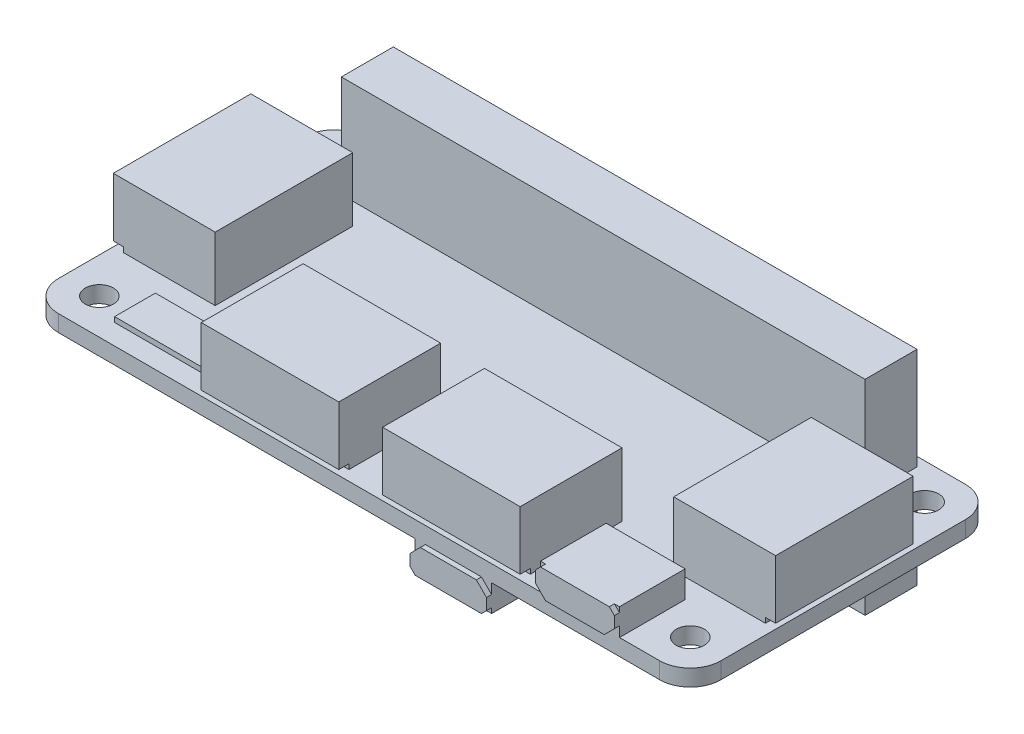
from build123d import *

# Parameters (mm, degrees)
EXTRUDE_1_DEPTH     = 1.62
CUT_EXTRUDE_1_REACH = 3.62
SKETCH_2_R          = 1.375
SKETCH_11_W         = 51.4
SKETCH_11_H         = 5.1
EXTRUDE_9_DEPTH     = 8.45
SKETCH_12_W         = 51.4
SKETCH_12_H         = 5.1
EXTRUDE_10_DEPTH    = 10
SKETCH_13_W         = 10
SKETCH_13_H         = 13.5
SKETCH_13_W_2       = 13.5
SKETCH_13_H_2       = 10
EXTRUDE_12_DEPTH    = 6.25
SKETCH_14_W         = 13.5
SKETCH_14_H         = 0.5
CUT_EXTRUDE_2_DEPTH = 1
SKETCH_15_W         = 13.5
SKETCH_15_H         = 0.5
CUT_EXTRUDE_3_DEPTH = 1
SKETCH_16_W         = 13.5
SKETCH_16_H         = 0.5
CUT_EXTRUDE_4_DEPTH = 1
SKETCH_17_W         = 7.75
SKETCH_17_H         = 6.44
EXTRUDE_13_DEPTH    = 2.62
EXTRUDE_14_DEPTH    = 0.5
SKETCH_19_W         = 8.5
SKETCH_19_H         = 4
EXTRUDE_15_DEPTH    = 0.5
SKETCH_20_W         = 7.5
SKETCH_20_H         = 5.146384945
EXTRUDE_16_DEPTH    = 2.62
EXTRUDE_17_DEPTH    = 0.5


with BuildPart() as part:
    # 草图1 → 凸台-拉伸1 (new body)
    with BuildSketch(Plane(origin=(0, 0, 0), x_dir=(1, 0, 0), z_dir=(0, 1, 0))):
        with BuildLine():
            Line((-29.5, 15), (29.5, 15))
            ThreePointArc((29.5, 15), (31.621320344, 14.121320344), (32.5, 12))
            Line((32.5, 12), (32.5, -12))
            ThreePointArc((32.5, -12), (31.621320344, -14.121320344), (29.5, -15))
            Line((29.5, -15), (-29.5, -15))
            ThreePointArc((-29.5, -15), (-31.621320344, -14.121320344), (-32.5, -12))
            Line((-32.5, -12), (-32.5, 12))
            ThreePointArc((-32.5, 12), (-31.621320344, 14.121320344), (-29.5, 15))
        make_face()
    extrude(amount=EXTRUDE_1_DEPTH)

    # 草图2 → 切除-拉伸1 (cut, up to next)
    with BuildSketch(Plane(origin=(0, 1.62, 0), x_dir=(1, 0, 0), z_dir=(0, 1, 0)), mode=Mode.PRIVATE) as cut_extrude_1_sk1:
        with Locations(Location((29, -11.5, 0), (0, 0, 270))):  # turned: the seam where the file's is
            Circle(SKETCH_2_R)
    cut_extrude_1_tool1 = extrude(cut_extrude_1_sk1.sketch, amount=-CUT_EXTRUDE_1_REACH, mode=Mode.PRIVATE) & part.part
    add(cut_extrude_1_tool1.solids().sort_by_distance((29, 1.62, 11.5))[0], mode=Mode.SUBTRACT)
    # 草图2 → 切除-拉伸1 (cut, up to next)
    with BuildSketch(Plane(origin=(0, 1.62, 0), x_dir=(1, 0, 0), z_dir=(0, 1, 0)), mode=Mode.PRIVATE) as cut_extrude_1_sk2:
        with Locations(Location((29, 11.5, 0), (0, 0, 270))):  # turned: the seam where the file's is
            Circle(SKETCH_2_R)
    cut_extrude_1_tool2 = extrude(cut_extrude_1_sk2.sketch, amount=-CUT_EXTRUDE_1_REACH, mode=Mode.PRIVATE) & part.part
    add(cut_extrude_1_tool2.solids().sort_by_distance((29, 1.62, -11.5))[0], mode=Mode.SUBTRACT)
    # 草图2 → 切除-拉伸1 (cut, up to next)
    with BuildSketch(Plane(origin=(0, 1.62, 0), x_dir=(1, 0, 0), z_dir=(0, 1, 0)), mode=Mode.PRIVATE) as cut_extrude_1_sk3:
        with Locations(Location((-29, -11.5, 0), (0, 0, 270))):  # turned: the seam where the file's is
            Circle(SKETCH_2_R)
    cut_extrude_1_tool3 = extrude(cut_extrude_1_sk3.sketch, amount=-CUT_EXTRUDE_1_REACH, mode=Mode.PRIVATE) & part.part
    add(cut_extrude_1_tool3.solids().sort_by_distance((-29, 1.62, 11.5))[0], mode=Mode.SUBTRACT)
    # 草图2 → 切除-拉伸1 (cut, up to next)
    with BuildSketch(Plane(origin=(0, 1.62, 0), x_dir=(1, 0, 0), z_dir=(0, 1, 0)), mode=Mode.PRIVATE) as cut_extrude_1_sk4:
        with Locations(Location((-29, 11.5, 0), (0, 0, 270))):  # turned: the seam where the file's is
            Circle(SKETCH_2_R)
    cut_extrude_1_tool4 = extrude(cut_extrude_1_sk4.sketch, amount=-CUT_EXTRUDE_1_REACH, mode=Mode.PRIVATE) & part.part
    add(cut_extrude_1_tool4.solids().sort_by_distance((-29, 1.62, -11.5))[0], mode=Mode.SUBTRACT)

    # 草图11 → 凸台-拉伸9 (add)
    with BuildSketch(Plane.XZ):
        with Locations((-0.05, -11.55)):
            Rectangle(SKETCH_11_W, SKETCH_11_H)
    extrude(amount=EXTRUDE_9_DEPTH)

    # 草图12 → 凸台-拉伸10 (add)
    with BuildSketch(Plane(origin=(0, 1.62, 0), x_dir=(1, 0, 0), z_dir=(0, 1, 0))):
        with Locations((-0.05, 11.55)):
            Rectangle(SKETCH_12_W, SKETCH_12_H)
    extrude(amount=EXTRUDE_10_DEPTH)

    # 草图13 → 凸台-拉伸12 (add)
    with BuildSketch(Plane(origin=(0, 1.62, 0), x_dir=(1, 0, 0), z_dir=(0, 1, 0))):
        with Locations((-27.5, 0.12)):
            Rectangle(SKETCH_13_W, SKETCH_13_H)
        with Locations((27.5, 0.12)):
            Rectangle(SKETCH_13_W, SKETCH_13_H)
        with Locations((-8.75, -10)):
            Rectangle(SKETCH_13_W_2, SKETCH_13_H_2)
        with Locations((9.05, -10)):
            Rectangle(SKETCH_13_W_2, SKETCH_13_H_2)
    extrude(amount=EXTRUDE_12_DEPTH)

    # 草图14 → 切除-拉伸2 (cut)
    with BuildSketch(Plane.XY.offset(15)):
        with Locations((-8.75, 1.87)):
            Rectangle(SKETCH_14_W, SKETCH_14_H)
        with Locations((9.05, 1.87)):
            Rectangle(SKETCH_14_W, SKETCH_14_H)
    extrude(amount=-CUT_EXTRUDE_2_DEPTH, mode=Mode.SUBTRACT)

    # 草图15 → 切除-拉伸3 (cut)
    with BuildSketch(Plane.ZY.offset(32.5)):
        with Locations((-0.12, 1.87)):
            Rectangle(SKETCH_15_W, SKETCH_15_H)
    extrude(amount=-CUT_EXTRUDE_3_DEPTH, mode=Mode.SUBTRACT)

    # 草图16 → 切除-拉伸4 (cut)
    with BuildSketch(Plane(origin=(32.5, 0, 0), x_dir=(0, 0, -1), z_dir=(1, 0, 0))):
        with Locations((0.12, 1.87)):
            Rectangle(SKETCH_16_W, SKETCH_16_H)
    extrude(amount=-CUT_EXTRUDE_4_DEPTH, mode=Mode.SUBTRACT)

    # 草图17 → 凸台-拉伸13 (add)
    with BuildSketch(Plane(origin=(0, 1.62, 0), x_dir=(1, 0, 0), z_dir=(0, 1, 0))):
        with Locations((21.675, -11.78)):
            Rectangle(SKETCH_17_W, SKETCH_17_H)
    extrude(amount=EXTRUDE_13_DEPTH)

    # 草图18 → 凸台-拉伸14 (add)
    with BuildSketch(Plane.XY.offset(15)):
        Polygon((17.8, 2.62), (18.8, 1.62), (24.55, 1.62), (25.55, 2.62), (25.55, 3.74), (25.05, 4.24), (18.3, 4.24), (17.8, 3.74), align=None)
    extrude(amount=EXTRUDE_14_DEPTH)

    # 草图19 → 凸台-拉伸15 (add)
    with BuildSketch(Plane(origin=(0, 1.62, 0), x_dir=(1, 0, 0), z_dir=(0, 1, 0))):
        with Locations((-21.75, -11)):
            Rectangle(SKETCH_19_W, SKETCH_19_H)
    extrude(amount=EXTRUDE_15_DEPTH)

    # 草图20 → 凸台-拉伸16 (add)
    with BuildSketch(Plane.XZ):
        with Locations((9.25, 12.426807528)):
            Rectangle(SKETCH_20_W, SKETCH_20_H)
    extrude(amount=EXTRUDE_16_DEPTH)

    # 草图21 → 凸台-拉伸17 (add)
    with BuildSketch(Plane.XY.offset(15)):
        Polygon((6.5, 0), (12, 0), (13, -1), (13, -2.12), (12.5, -2.62), (6, -2.62), (5.5, -2.12), (5.5, -1), align=None)
    extrude(amount=EXTRUDE_17_DEPTH)


solid = part.part
